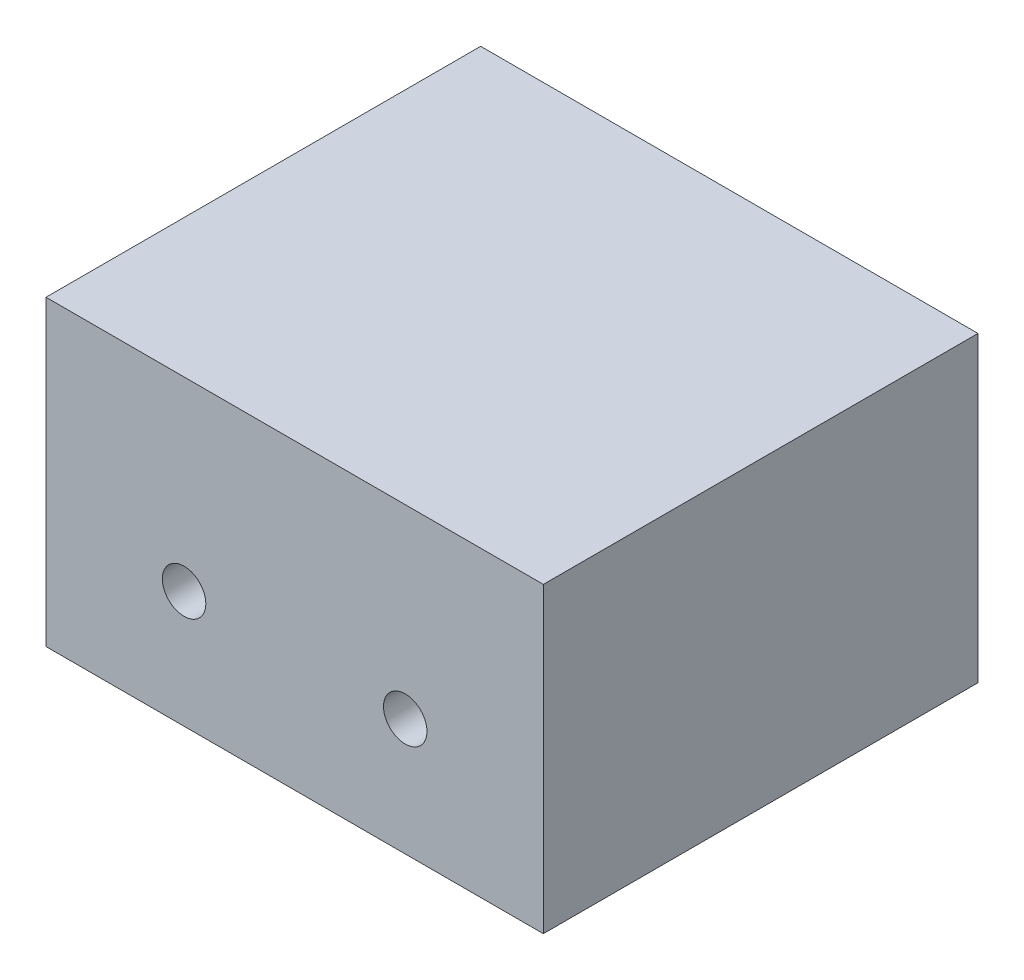
from build123d import *

# Parameters (mm, degrees)
SKETCH1_W           = 57.21
SKETCH1_H           = 50
BOSS_EXTRUDE1_DEPTH = 34.8
SKETCH2_R           = 2.5
CUT_EXTRUDE1_DEPTH  = 51


with BuildPart() as part:
    # Sketch1 → Boss-Extrude1 (new body)
    with BuildSketch(Plane(origin=(0, 0, 0), x_dir=(1, 0, 0), z_dir=(0, 1, 0))):
        Rectangle(SKETCH1_W, SKETCH1_H)
    extrude(amount=BOSS_EXTRUDE1_DEPTH)

    # Sketch2 → Cut-Extrude1 (cut, through all)
    with BuildSketch(Plane.XY.offset(25)):
        with Locations((-12.72, 13.45)):
            Circle(SKETCH2_R)
    cut_extrude1 = extrude(amount=-CUT_EXTRUDE1_DEPTH, mode=Mode.SUBTRACT)

    # Mirror1: Cut-Extrude1 across plane
    add(cut_extrude1.mirror(Plane(origin=(0, 0, 0), x_dir=(0, 0, 1), z_dir=(1, 0, 0))), mode=Mode.SUBTRACT)


solid = part.part
